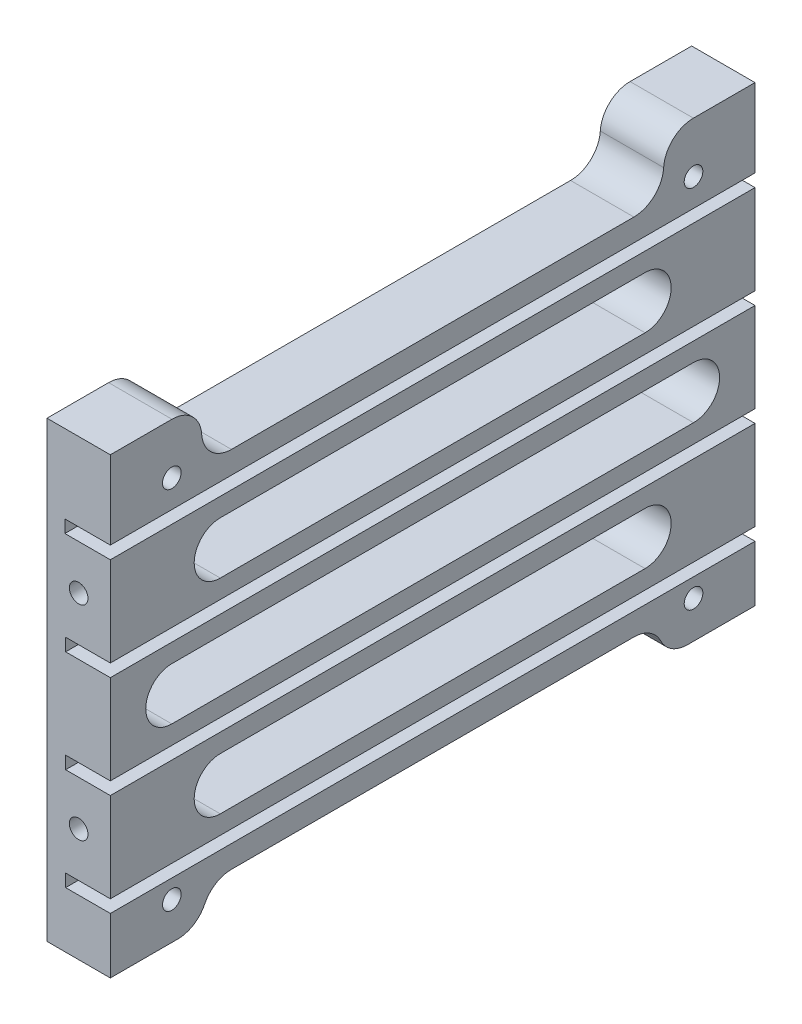
from build123d import *

# Parameters (mm, degrees)
BOSS_EXTRUDE1_DEPTH            = 86.5
M3X0_5_TAPPED_HOLE2_AT_2_COUNT = 2
M3X0_5_TAPPED_HOLE2_AT_2_PITCH = 27.4
M3X0_5_TAPPED_HOLE1_D          = 2.5
SKETCH14_R                     = 3.5
CUT_EXTRUDE3_DEPTH             = 9.5
CUT_EXTRUDE1_DEPTH             = 9.5
SKETCH15_W                     = 62
SKETCH15_H                     = 7.5
CUT_EXTRUDE4_DEPTH             = 9.5
SKETCH16_W                     = 62
SKETCH16_H                     = 4.5
CUT_EXTRUDE5_DEPTH             = 9.5
FILLET2_R                      = 4
FILLET3_R                      = 4


with BuildPart() as part:
    # Sketch1 → Boss-Extrude1 (new body)
    with BuildSketch(Plane.XY):
        Polygon((0, 0), (0, 60.8), (8.5, 60.8), (8.5, 50.3), (2.4, 50.3), (2.4, 48.6), (8.5, 48.6), (8.5, 36.6), (2.5, 36.6), (2.5, 34.9), (8.5, 34.9), (8.5, 22.9), (2.5, 22.9), (2.5, 21.2), (8.5, 21.2), (8.5, 9.2), (2.5, 9.2), (2.5, 7.5), (8.5, 7.5), (8.5, 0), align=None)
    extrude(amount=BOSS_EXTRUDE1_DEPTH)

    # Sketch4 → M3x0.5 Tapped Hole2 (revolve, cut)
    with BuildSketch(Plane(origin=(4.25, 42.6, 86.5), x_dir=(0, -1, 0), z_dir=(1, 0, 0))):
        Polygon((0, 0), (0, 6.751075774), (1.25, 6), (1.25, 0), align=None)
    m3x0_5_tapped_hole2 = revolve(axis=Axis((4.25, 42.6, 92.85), (0, 0, -1)), mode=Mode.SUBTRACT)

    # M3x0.5 Tapped Hole2 at 2: M3x0.5 Tapped Hole2 ×2
    with Locations(*[(0, -i * M3X0_5_TAPPED_HOLE2_AT_2_PITCH, 0) for i in range(1, M3X0_5_TAPPED_HOLE2_AT_2_COUNT)]):
        add(m3x0_5_tapped_hole2, mode=Mode.SUBTRACT)

    # Mirror1: M3x0.5 Tapped Hole2 across plane
    add(m3x0_5_tapped_hole2.mirror(Plane.XY.offset(43.25)), mode=Mode.SUBTRACT)

    # Mirror1 copy 1 sketch → Mirror1 copy 1 (revolve, cut)
    with BuildSketch(Plane(origin=(4.25, 15.2, 0), x_dir=(0, -1, 0), z_dir=(1, 0, 0))):
        Polygon((0, 0), (0, -6.751075774), (1.25, -6), (1.25, 0), align=None)
    revolve(axis=Axis((4.25, 15.2, -6.35), (0, 0, -1)), mode=Mode.SUBTRACT)

    # M3x0.5 Tapped Hole1 (through all)
    with Locations(Plane.ZY):
        with Locations((8.25, 5), (8.25, 54)):
            m3x0_5_tapped_hole1 = Hole(M3X0_5_TAPPED_HOLE1_D / 2)

    # Mirror2: M3x0.5 Tapped Hole1 across plane
    add(m3x0_5_tapped_hole1.mirror(Plane(origin=(0, 0, 43.25), x_dir=(1, 0, 0), z_dir=(0, 0, -1))), mode=Mode.SUBTRACT)

    # Sketch14 → Cut-Extrude3 (cut, through all)
    with BuildSketch(Plane(origin=(8.5, 0, 0), x_dir=(0, 0, -1), z_dir=(1, 0, 0))):
        with BuildLine():
            Line((-8.25, 32.4), (-78.25, 32.4))
            ThreePointArc((-78.25, 32.4), (-75.775126266, 31.374873734), (-74.75, 28.9))
            ThreePointArc((-74.75, 28.9), (-75.775126266, 26.425126266), (-78.25, 25.4))
            Line((-78.25, 25.4), (-8.25, 25.4))
            ThreePointArc((-8.25, 25.4), (-11.75, 28.9), (-8.25, 32.4))
        make_face()
        with Locations((-78.25, 28.9)):
            Circle(SKETCH14_R)
        with Locations((-8.25, 28.9)):
            Circle(SKETCH14_R)
    extrude(amount=-CUT_EXTRUDE3_DEPTH, mode=Mode.SUBTRACT)

    # Sketch12 → Cut-Extrude1 (cut, through all)
    with BuildSketch(Plane(origin=(8.5, 0, 0), x_dir=(0, 0, -1), z_dir=(1, 0, 0))):
        with BuildLine():
            Line((-14.75, 46.1), (-71.75, 46.1))
            ThreePointArc((-71.75, 46.1), (-75.25, 42.6), (-71.75, 39.1))
            Line((-71.75, 39.1), (-14.75, 39.1))
            ThreePointArc((-14.75, 39.1), (-11.25, 42.6), (-14.75, 46.1))
        make_face()
        with BuildLine():
            Line((-14.75, 18.7), (-71.75, 18.7))
            ThreePointArc((-71.75, 18.7), (-75.25, 15.2), (-71.75, 11.7))
            Line((-71.75, 11.7), (-14.75, 11.7))
            ThreePointArc((-14.75, 11.7), (-11.25, 15.2), (-14.75, 18.7))
        make_face()
    extrude(amount=-CUT_EXTRUDE1_DEPTH, mode=Mode.SUBTRACT)

    # Sketch15 → Cut-Extrude4 (cut, through all)
    with BuildSketch(Plane(origin=(8.5, 0, 0), x_dir=(0, 0, -1), z_dir=(1, 0, 0))):
        with Locations((-43.25, 57.05)):
            Rectangle(SKETCH15_W, SKETCH15_H)
    extrude(amount=-CUT_EXTRUDE4_DEPTH, mode=Mode.SUBTRACT)

    # Sketch16 → Cut-Extrude5 (cut, through all)
    with BuildSketch(Plane(origin=(8.5, 0, 0), x_dir=(0, 0, -1), z_dir=(1, 0, 0))):
        with Locations((-43.25, 2.25)):
            Rectangle(SKETCH16_W, SKETCH16_H)
    extrude(amount=-CUT_EXTRUDE5_DEPTH, mode=Mode.SUBTRACT)

    # Fillet2
    fillet2_edges = [part.edges().sort_by_distance(p)[0] for p in [
        (4.25, 53.3, 12.25),
        (4.25, 53.3, 74.25),
        (4.25, 4.5, 12.25),
        (4.25, 4.5, 74.25),
    ]]
    fillet(fillet2_edges, radius=FILLET2_R)

    # Fillet3
    fillet3_edges = [part.edges().sort_by_distance(p)[0] for p in [
        (4.25, 0, 12.25),
        (4.25, 0, 74.25),
        (4.25, 60.8, 12.25),
        (4.25, 60.8, 74.25),
    ]]
    fillet(fillet3_edges, radius=FILLET3_R)


solid = part.part
